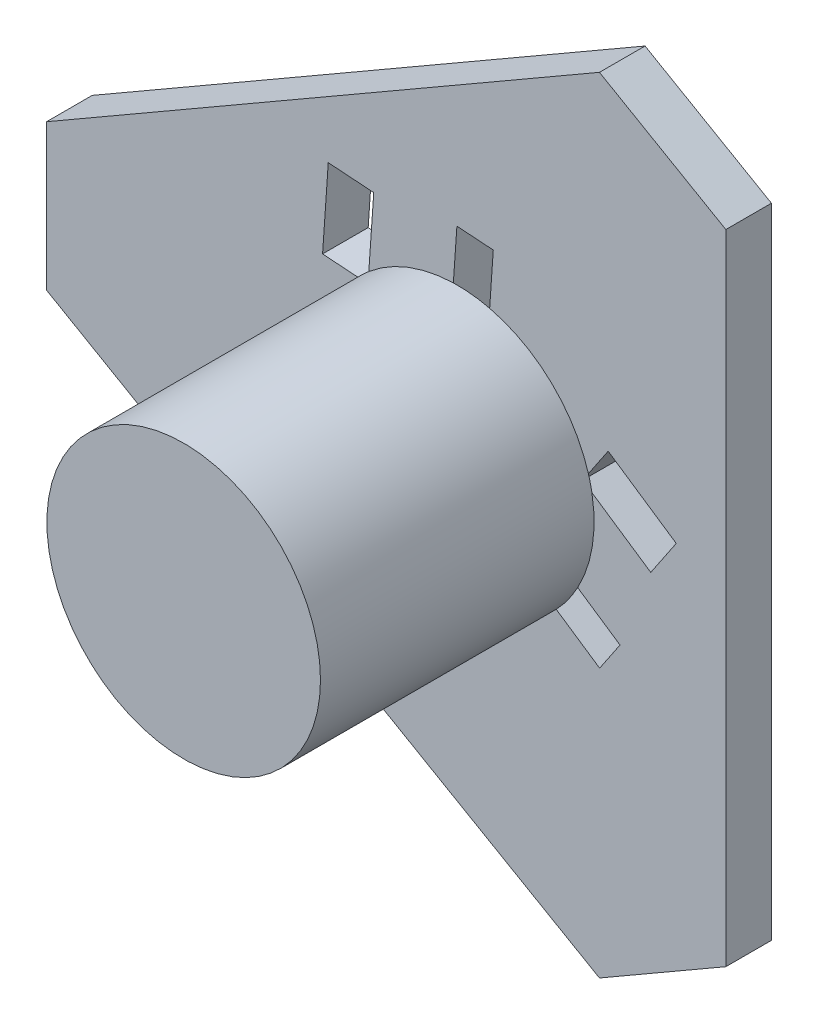
from build123d import *

# Parameters (mm, degrees)
BOSS_EXTRUDE1_DEPTH = 5
CUT_EXTRUDE7_DEPTH  = 63.465990747
CIRPATTERN1_COUNT   = 3
SKETCH11_R          = 15
BOSS_EXTRUDE2_DEPTH = 30


with BuildPart() as part:
    # Sketch1 → Boss-Extrude1 (new body)
    with BuildSketch(Plane.XY):
        Polygon((-45.033320997, -8), (-45.033320997, 8), (15.588457268, 43), (29.444863729, 35), (29.444863729, -35), (15.588457268, -43), align=None)
    extrude(amount=BOSS_EXTRUDE1_DEPTH)

    # Sketch9 → Cut-Extrude7 (cut, through all)
    with BuildSketch(Plane.XY.offset(5)):
        Polygon((-19.556667785, -6.732996787), (-7.875286887, -1.028144438), (-6.119947703, -4.622415484), (-17.801328601, -10.327267832), align=None)
        Polygon((-12.054679914, -17.536708093), (-3.967570061, -13.587194928), (-1.773396081, -18.080033735), (-9.860505933, -22.029546899), align=None)
    cut_extrude7 = extrude(amount=-CUT_EXTRUDE7_DEPTH, mode=Mode.SUBTRACT)

    # CirPattern1: Cut-Extrude7 ×3 about axis
    cirpattern1_axis = Axis((0, 0, 0), (0, 0, 1))
    for i in range(1, CIRPATTERN1_COUNT):
        add(cut_extrude7.rotate(cirpattern1_axis, i * 360 / CIRPATTERN1_COUNT), mode=Mode.SUBTRACT)

    # Sketch11 → Boss-Extrude2 (add)
    with BuildSketch(Plane.XY.offset(5)):
        Circle(SKETCH11_R)
    extrude(amount=BOSS_EXTRUDE2_DEPTH)


solid = part.part
